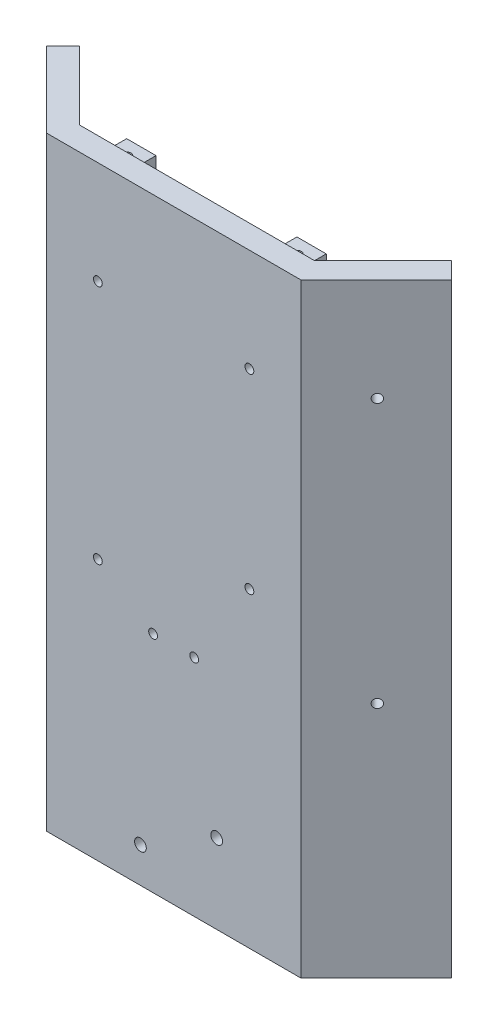
from build123d import *

# Parameters (mm, degrees)
BOSS_EXTRUDE1_DEPTH            = 206
SKETCH2_W                      = 10
SKETCH2_H                      = 6
BOSS_EXTRUDE2_DEPTH            = 10
CUT_EXTRUDE1_REACH             = 202
SKETCH3_R                      = 1.5
CUT_EXTRUDE2_REACH             = 33.335
SKETCH4_R                      = 2
CUT_EXTRUDE3_REACH             = 33.335
SKETCH5_R                      = 1.5
CUT_EXTRUDE4_REACH             = 33.335
SKETCH6_R                      = 1.5
CUT_EXTRUDE5_REACH             = 103.569
SKETCH7_R                      = 1.5
CUT_EXTRUDE5_DIRECTION_2_DEPTH = 19.156854249
CUT_EXTRUDE6_REACH             = 103.569
SKETCH9_R                      = 1.5


with BuildPart() as part:
    # Sketch1 → Boss-Extrude1 (new body)
    with BuildSketch(Plane(origin=(0, 0, 0), x_dir=(1, 0, 0), z_dir=(0, 1, 0))):
        Polygon((-40, 0), (40, 0), (63.334523779, 23.334523779), (68.991378029, 17.67766953), (43.313708499, -8), (-43.313708499, -8), (-68.991378029, 17.67766953), (-63.334523779, 23.334523779), align=None)
    extrude(amount=BOSS_EXTRUDE1_DEPTH)

    # Sketch2 → Boss-Extrude2 (add)
    with BuildSketch(Plane(origin=(0, 0, 0), x_dir=(-1, 0, 0), z_dir=(0, 0, -1))):
        with Locations((-29, 197)):
            Rectangle(SKETCH2_W, SKETCH2_H)
        with Locations((29, 197)):
            Rectangle(SKETCH2_W, SKETCH2_H)
    extrude(amount=BOSS_EXTRUDE2_DEPTH)

    # Sketch3 → Cut-Extrude1 (cut, up to next)
    with BuildSketch(Plane(origin=(0, 200, 0), x_dir=(1, 0, 0), z_dir=(0, 1, 0)), mode=Mode.PRIVATE) as cut_extrude1_sk1:
        with Locations((-29, 5)):
            Circle(SKETCH3_R)
    cut_extrude1_tool1 = extrude(cut_extrude1_sk1.sketch, amount=-CUT_EXTRUDE1_REACH, mode=Mode.PRIVATE) & part.part
    add(cut_extrude1_tool1.solids().sort_by_distance((-29, 200, -5))[0], mode=Mode.SUBTRACT)
    # Sketch3 → Cut-Extrude1 (cut, up to next)
    with BuildSketch(Plane(origin=(0, 200, 0), x_dir=(1, 0, 0), z_dir=(0, 1, 0)), mode=Mode.PRIVATE) as cut_extrude1_sk2:
        with Locations((29, 5)):
            Circle(SKETCH3_R)
    cut_extrude1_tool2 = extrude(cut_extrude1_sk2.sketch, amount=-CUT_EXTRUDE1_REACH, mode=Mode.PRIVATE) & part.part
    add(cut_extrude1_tool2.solids().sort_by_distance((29, 200, -5))[0], mode=Mode.SUBTRACT)

    # Sketch4 → Cut-Extrude2 (cut, up to next)
    with BuildSketch(Plane.XY.offset(8), mode=Mode.PRIVATE) as cut_extrude2_sk1:
        with Locations((-11.313708499, 12)):
            Circle(SKETCH4_R)
    cut_extrude2_tool1 = extrude(cut_extrude2_sk1.sketch, amount=-CUT_EXTRUDE2_REACH, mode=Mode.PRIVATE) & part.part
    add(cut_extrude2_tool1.solids().sort_by_distance((-11.313708, 12, 8))[0], mode=Mode.SUBTRACT)
    # Sketch4 → Cut-Extrude2 (cut, up to next)
    with BuildSketch(Plane.XY.offset(8), mode=Mode.PRIVATE) as cut_extrude2_sk2:
        with Locations((14.667053615, 27)):
            Circle(SKETCH4_R)
    cut_extrude2_tool2 = extrude(cut_extrude2_sk2.sketch, amount=-CUT_EXTRUDE2_REACH, mode=Mode.PRIVATE) & part.part
    add(cut_extrude2_tool2.solids().sort_by_distance((14.667054, 27, 8))[0], mode=Mode.SUBTRACT)

    # Sketch5 → Cut-Extrude3 (cut, up to next)
    with BuildSketch(Plane.XY.offset(8), mode=Mode.PRIVATE) as cut_extrude3_sk1:
        with Locations((7, 76.404082058)):
            Circle(SKETCH5_R)
    cut_extrude3_tool1 = extrude(cut_extrude3_sk1.sketch, amount=-CUT_EXTRUDE3_REACH, mode=Mode.PRIVATE) & part.part
    add(cut_extrude3_tool1.solids().sort_by_distance((7, 76.404082, 8))[0], mode=Mode.SUBTRACT)
    # Sketch5 → Cut-Extrude3 (cut, up to next)
    with BuildSketch(Plane.XY.offset(8), mode=Mode.PRIVATE) as cut_extrude3_sk2:
        with Locations((-7, 76.404082058)):
            Circle(SKETCH5_R)
    cut_extrude3_tool2 = extrude(cut_extrude3_sk2.sketch, amount=-CUT_EXTRUDE3_REACH, mode=Mode.PRIVATE) & part.part
    add(cut_extrude3_tool2.solids().sort_by_distance((-7, 76.404082, 8))[0], mode=Mode.SUBTRACT)

    # Sketch6 → Cut-Extrude4 (cut, up to next)
    with BuildSketch(Plane.XY.offset(8), mode=Mode.PRIVATE) as cut_extrude4_sk1:
        with Locations((25.813708499, 171)):
            Circle(SKETCH6_R)
    cut_extrude4_tool1 = extrude(cut_extrude4_sk1.sketch, amount=-CUT_EXTRUDE4_REACH, mode=Mode.PRIVATE) & part.part
    add(cut_extrude4_tool1.solids().sort_by_distance((25.813708, 171, 8))[0], mode=Mode.SUBTRACT)
    # Sketch6 → Cut-Extrude4 (cut, up to next)
    with BuildSketch(Plane.XY.offset(8), mode=Mode.PRIVATE) as cut_extrude4_sk2:
        with Locations((-25.813708499, 171)):
            Circle(SKETCH6_R)
    cut_extrude4_tool2 = extrude(cut_extrude4_sk2.sketch, amount=-CUT_EXTRUDE4_REACH, mode=Mode.PRIVATE) & part.part
    add(cut_extrude4_tool2.solids().sort_by_distance((-25.813708, 171, 8))[0], mode=Mode.SUBTRACT)
    # Sketch6 → Cut-Extrude4 (cut, up to next)
    with BuildSketch(Plane.XY.offset(8), mode=Mode.PRIVATE) as cut_extrude4_sk3:
        with Locations((25.813708499, 106)):
            Circle(SKETCH6_R)
    cut_extrude4_tool3 = extrude(cut_extrude4_sk3.sketch, amount=-CUT_EXTRUDE4_REACH, mode=Mode.PRIVATE) & part.part
    add(cut_extrude4_tool3.solids().sort_by_distance((25.813708, 106, 8))[0], mode=Mode.SUBTRACT)
    # Sketch6 → Cut-Extrude4 (cut, up to next)
    with BuildSketch(Plane.XY.offset(8), mode=Mode.PRIVATE) as cut_extrude4_sk4:
        with Locations((-25.813708499, 89)):
            Circle(SKETCH6_R)
    cut_extrude4_tool4 = extrude(cut_extrude4_sk4.sketch, amount=-CUT_EXTRUDE4_REACH, mode=Mode.PRIVATE) & part.part
    add(cut_extrude4_tool4.solids().sort_by_distance((-25.813708, 89, 8))[0], mode=Mode.SUBTRACT)

    # Sketch7 → Cut-Extrude5 (cut, up to next)
    with BuildSketch(Plane(origin=(25.656854249, 0, 25.656854249), x_dir=(0.707106781, 0, -0.707106781), z_dir=(0.707106781, 0, 0.707106781)), mode=Mode.PRIVATE) as cut_extrude5_sk1:
        with Locations((43.410562748, 171)):
            Circle(SKETCH7_R)
    cut_extrude5_tool1 = extrude(cut_extrude5_sk1.sketch, amount=-CUT_EXTRUDE5_REACH, mode=Mode.PRIVATE) & part.part
    add(cut_extrude5_tool1.solids().sort_by_distance((56.352758, 171, -5.039049))[0], mode=Mode.SUBTRACT)
    # Sketch7 → Cut-Extrude5 (cut, up to next)
    with BuildSketch(Plane(origin=(25.656854249, 0, 25.656854249), x_dir=(0.707106781, 0, -0.707106781), z_dir=(0.707106781, 0, 0.707106781)), mode=Mode.PRIVATE) as cut_extrude5_sk2:
        with Locations((43.410562748, 81)):
            Circle(SKETCH7_R)
    cut_extrude5_tool2 = extrude(cut_extrude5_sk2.sketch, amount=-CUT_EXTRUDE5_REACH, mode=Mode.PRIVATE) & part.part
    add(cut_extrude5_tool2.solids().sort_by_distance((56.352758, 81, -5.039049))[0], mode=Mode.SUBTRACT)

    # Sketch7 → Cut-Extrude5 direction 2 (cut)
    with BuildSketch(Plane(origin=(25.656854249, 0, 25.656854249), x_dir=(0.707106781, 0, -0.707106781), z_dir=(0.707106781, 0, 0.707106781))):
        with Locations((43.410562748, 171)):
            Circle(SKETCH7_R)
        with Locations((43.410562748, 81)):
            Circle(SKETCH7_R)
    extrude(amount=CUT_EXTRUDE5_DIRECTION_2_DEPTH, mode=Mode.SUBTRACT)

    # Sketch9 → Cut-Extrude6 (cut, up to next)
    with BuildSketch(Plane(origin=(-25.656854249, 0, 25.656854249), x_dir=(0.707106781, 0, 0.707106781), z_dir=(-0.707106781, 0, 0.707106781)), mode=Mode.PRIVATE) as cut_extrude6_sk1:
        with Locations((-40.384271247, 171)):
            Circle(SKETCH9_R)
    cut_extrude6_tool1 = extrude(cut_extrude6_sk1.sketch, amount=-CUT_EXTRUDE6_REACH, mode=Mode.PRIVATE) & part.part
    add(cut_extrude6_tool1.solids().sort_by_distance((-54.212846, 171, -2.899138))[0], mode=Mode.SUBTRACT)
    # Sketch9 → Cut-Extrude6 (cut, up to next)
    with BuildSketch(Plane(origin=(-25.656854249, 0, 25.656854249), x_dir=(0.707106781, 0, 0.707106781), z_dir=(-0.707106781, 0, 0.707106781)), mode=Mode.PRIVATE) as cut_extrude6_sk2:
        with Locations((-40.384271247, 76)):
            Circle(SKETCH9_R)
    cut_extrude6_tool2 = extrude(cut_extrude6_sk2.sketch, amount=-CUT_EXTRUDE6_REACH, mode=Mode.PRIVATE) & part.part
    add(cut_extrude6_tool2.solids().sort_by_distance((-54.212846, 76, -2.899138))[0], mode=Mode.SUBTRACT)


solid = part.part
